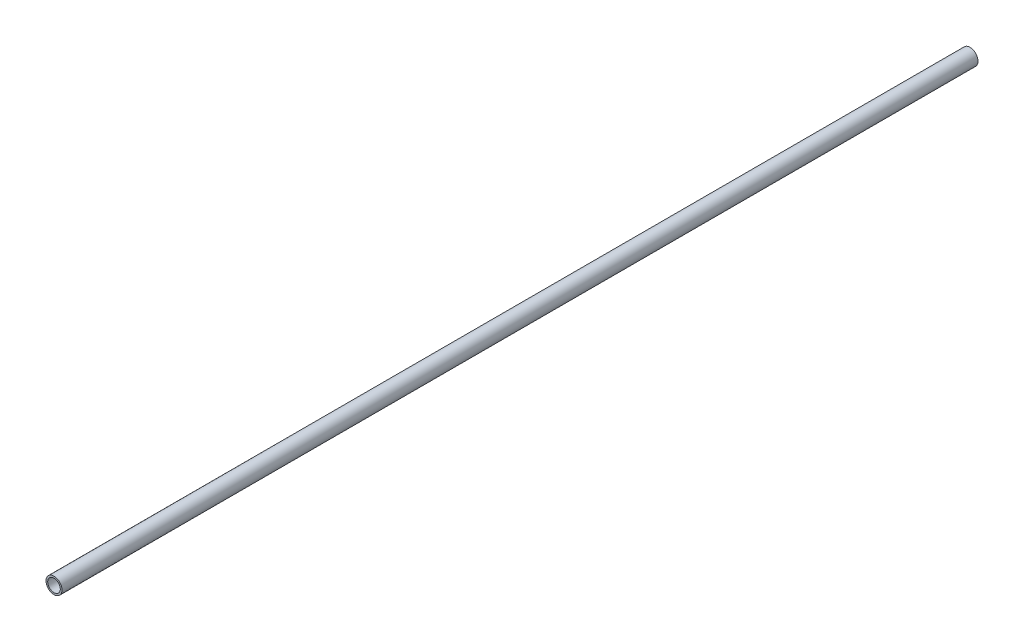
from build123d import *

# Parameters (mm, degrees)
SKETCH1_R           = 13.335
SKETCH1_R_2         = 10.4648
EXTRUDE_THIN1_DEPTH = 762


with BuildPart() as part:
    # Sketch1 → Extrude-Thin1 (new body, symmetric)
    with BuildSketch(Plane.XY):
        Circle(SKETCH1_R)
        Circle(SKETCH1_R_2, mode=Mode.SUBTRACT)
    extrude(amount=EXTRUDE_THIN1_DEPTH, both=True)


solid = part.part
